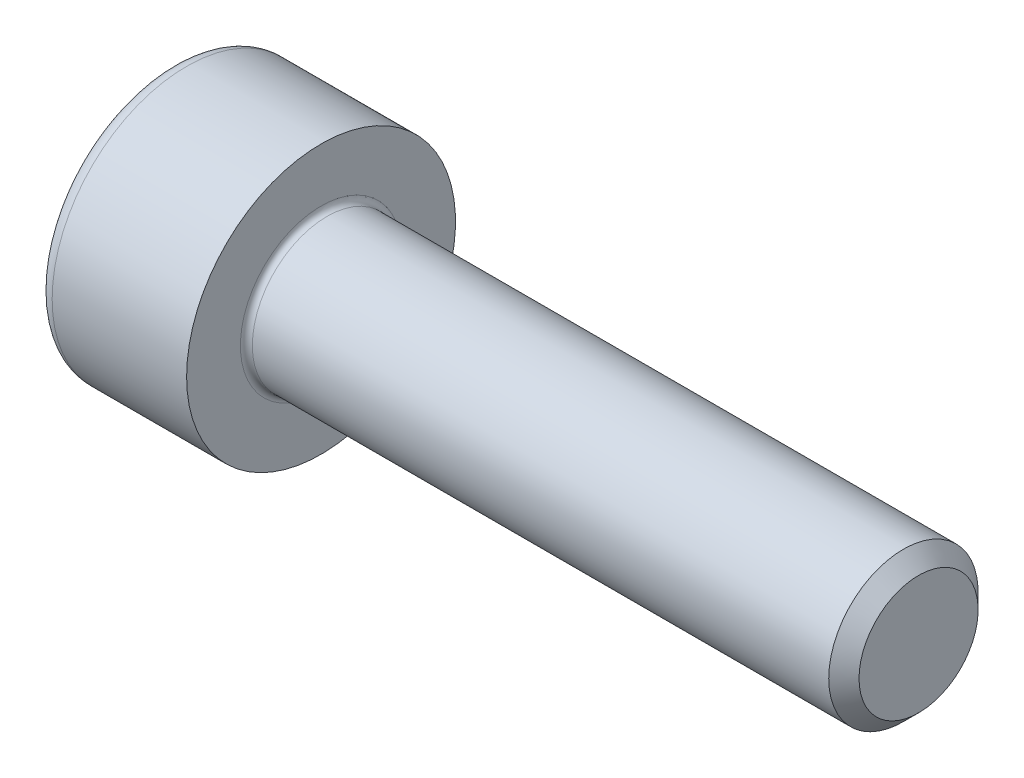
from build123d import *

# Parameters (mm, degrees)
FILLET1_R   = 0.1
FILLET2_R   = 0.25
HEX_2_DEPTH = 1.1


with BuildPart() as part:
    # BodySke → Base-Revolve (revolve)
    with BuildSketch(Plane.XY):
        Polygon((0, 0), (0, 2.25), (2.5, 2.25), (2.5, 1.25), (12.2465, 1.25), (12.5, 0.9965), (12.5, 0), align=None)
    revolve(axis=Axis((-31.75, 0, 0), (1, 0, 0)))

    # Fillet1
    fillet1_edges = [part.edges().sort_by_distance(p)[0] for p in [
        (2.5, -1.25, 0),
    ]]
    fillet(fillet1_edges, radius=FILLET1_R)

    # Fillet2
    fillet2_edges = [part.edges().sort_by_distance(p)[0] for p in [
        (0, -2.25, 0),
    ]]
    fillet(fillet2_edges, radius=FILLET2_R)

    # Sketch2 → Hex-PreBroach (revolve, cut)
    with BuildSketch(Plane.XY):
        Polygon((0, 1.01), (1.1, 1.01), (1.683123772, 0), (0, 0), align=None)
    revolve(axis=Axis((0, 0, 0), (1, 0, 0)), mode=Mode.SUBTRACT)

    # Sketch3 → Hex 2 (cut)
    with BuildSketch(Plane(origin=(0, 0, 0), x_dir=(0, 0.5, 0.866025404), z_dir=(-1, 0, 0))):
        Polygon((0.583123772, 1.01), (-0.583123772, 1.01), (-1.166247544, 0), (-0.583123772, -1.01), (0.583123772, -1.01), (1.166247544, 0), align=None)
    extrude(amount=-HEX_2_DEPTH, mode=Mode.SUBTRACT)


solid = part.part
